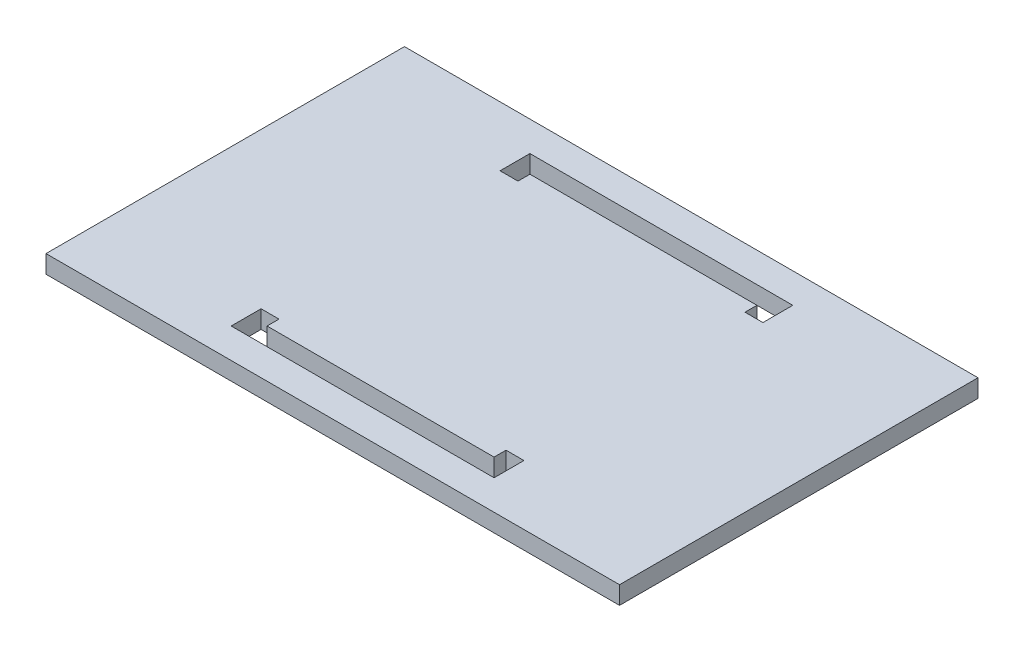
from build123d import *

# Parameters (mm, degrees)
SKETCH1_W           = 44
SKETCH1_H           = 5
BOSS_EXTRUDE1_DEPTH = 3


with BuildPart() as part:
    # Sketch1 → Boss-Extrude1 (new body)
    with BuildSketch(Plane(origin=(0, 0, 0), x_dir=(1, 0, 0), z_dir=(0, 1, 0))):
        with Locations((0, 27.5)):
            Rectangle(SKETCH1_W, SKETCH1_H)
        with Locations((0, -27.5)):
            Rectangle(SKETCH1_W, SKETCH1_H)
        Polygon((-22, -30), (-48, -30), (-48, 30), (-22, 30), (-22, 20), (-19, 20), (-19, 22), (19, 22), (19, 20), (22, 20), (22, 30), (48, 30), (48, -30), (22, -30), (22, -20), (19, -20), (19, -22), (-19, -22), (-19, -20), (-22, -20), align=None)
    extrude(amount=BOSS_EXTRUDE1_DEPTH)


solid = part.part
